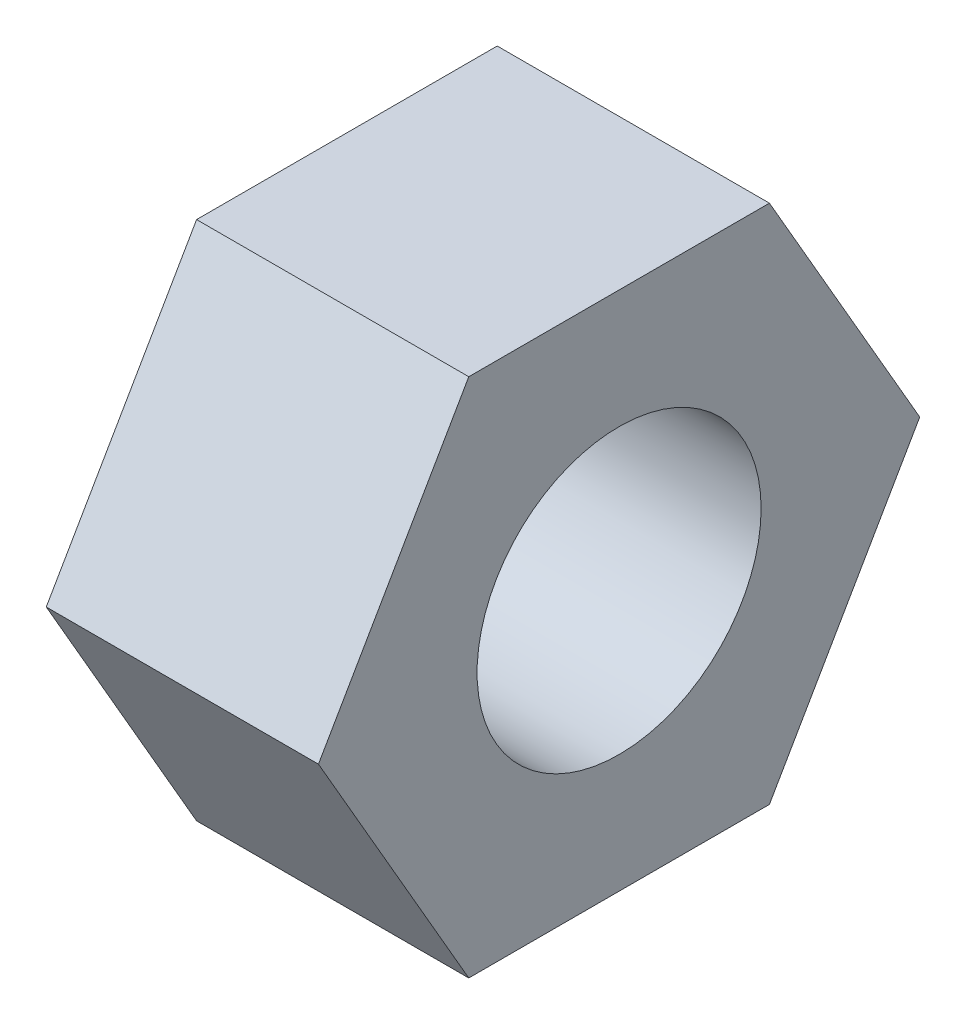
from build123d import *

# Parameters (mm, degrees)
SKETCH1_R           = 4.7625
BOSS_EXTRUDE1_DEPTH = 9.128125


with BuildPart() as part:
    # Sketch1 → Boss-Extrude1 (new body)
    with BuildSketch(Plane(origin=(0, 0, 0), x_dir=(0, 0, -1), z_dir=(1, 0, 0))):
        Polygon((-10.081979076, 0), (-5.040989538, -8.73125), (5.040989538, -8.73125), (10.081979076, 0), (5.040989538, 8.73125), (-5.040989538, 8.73125), align=None)
        Circle(SKETCH1_R, mode=Mode.SUBTRACT)
    extrude(amount=BOSS_EXTRUDE1_DEPTH)


solid = part.part
